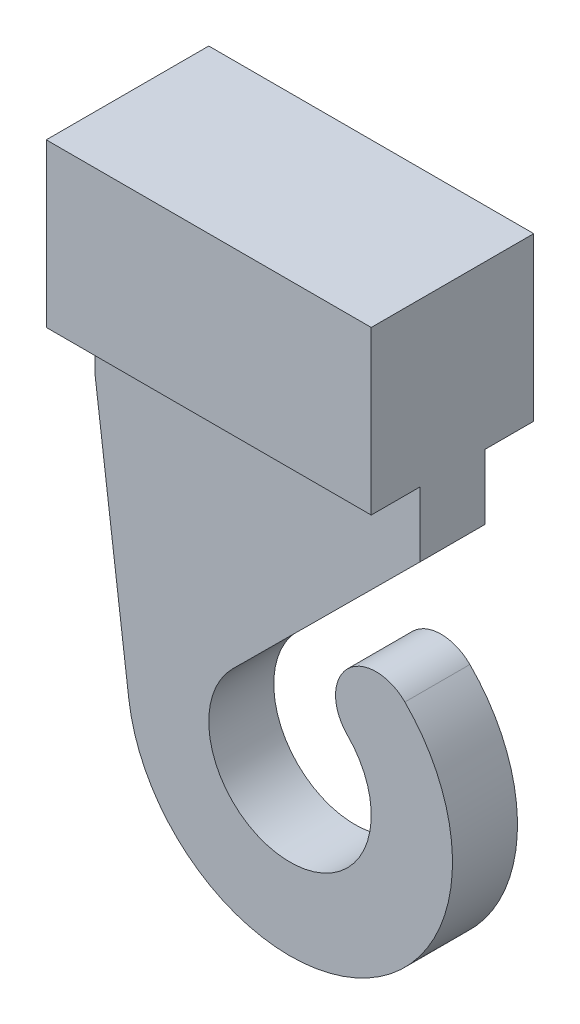
from build123d import *

# Parameters (mm, degrees)
SKETCH_1_W      = 5
SKETCH_1_H      = 5
SKETCH_1_W_2    = 3
SKETCH_1_H_2    = 3
EXTRUDE_1_DEPTH = 8
SKETCH_2_W      = 5
SKETCH_2_H      = 5
EXTRUDE_2_DEPTH = 2
SKETCH_3_W      = 10
SKETCH_3_H      = 2
EXTRUDE_3_DEPTH = 2
EXTRUDE_4_DEPTH = 2


with BuildPart() as part:
    # 草图1 → 凸台-拉伸1 (new body)
    with BuildSketch(Plane(origin=(0, 0, 0), x_dir=(0, 0, -1), z_dir=(1, 0, 0))):
        Rectangle(SKETCH_1_W, SKETCH_1_H)
        Rectangle(SKETCH_1_W_2, SKETCH_1_H_2, mode=Mode.SUBTRACT)
    extrude(amount=EXTRUDE_1_DEPTH)

    # 草图2 → 凸台-拉伸2 (add)
    with BuildSketch(Plane(origin=(8, 0, 0), x_dir=(0, 0, -1), z_dir=(1, 0, 0))):
        Rectangle(SKETCH_2_W, SKETCH_2_H)
    extrude(amount=EXTRUDE_2_DEPTH)

    # 草图3 → 凸台-拉伸3 (add)
    with BuildSketch(Plane.XZ.offset(2.5)):
        with Locations((5, 0)):
            Rectangle(SKETCH_3_W, SKETCH_3_H)
    extrude(amount=EXTRUDE_3_DEPTH)

    # 草图4 → 凸台-拉伸4 (add)
    with BuildSketch(Plane.XY.offset(1)):
        with BuildLine():
            Line((10, -4.5), (0, -4.5))
            Line((0, -4.5), (1.040402547, -12.634344629))
            ThreePointArc((1.040402547, -12.634344629), (8.203170669, -16.488433915), (9.535533906, -8.464466094))
            ThreePointArc((9.535533906, -8.464466094), (7.767766953, -8.464466094), (7.767766953, -10.232233047))
            ThreePointArc((7.767766953, -10.232233047), (5.996135796, -14.499997014), (4.237706296, -10.226776691))
            Line((4.237706296, -10.226776691), (7.30901916, -7.174394459))
            Line((7.30901916, -7.174394459), (10, -4.5))
        make_face()
    extrude(amount=-EXTRUDE_4_DEPTH)


solid = part.part
